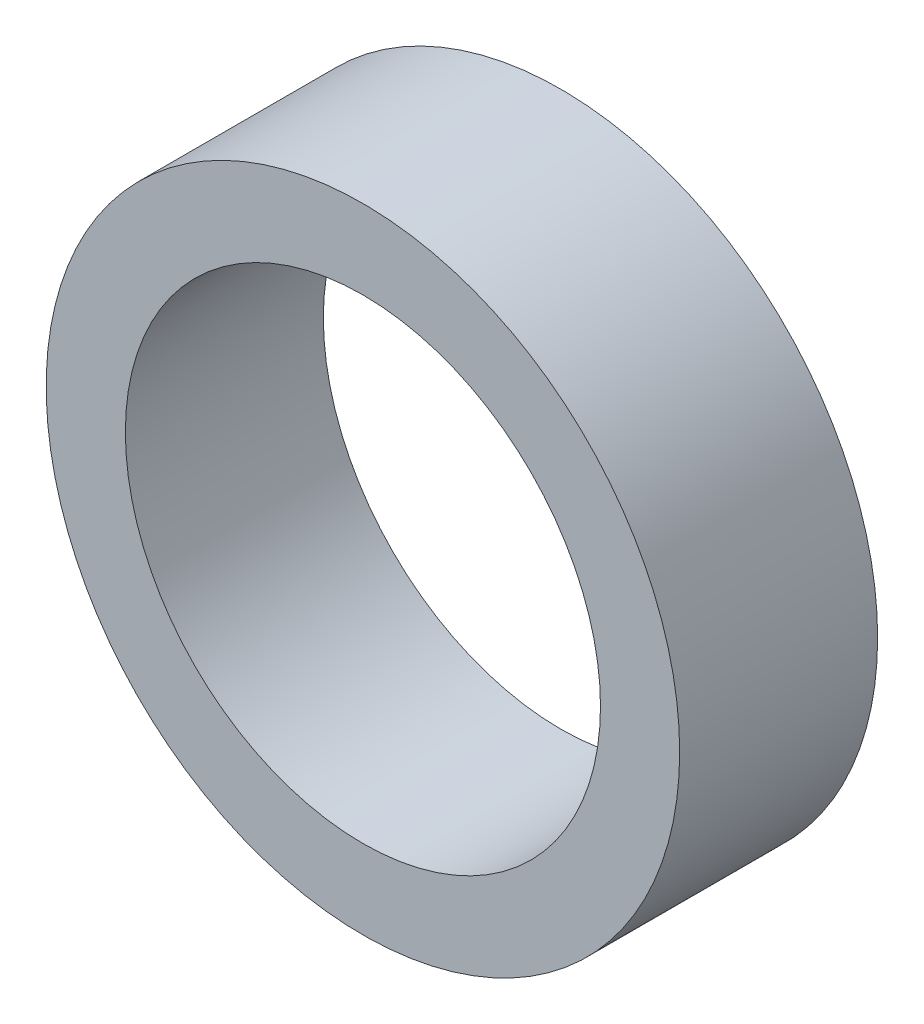
from build123d import *

# Parameters (mm, degrees)
CROQUIS3_R              = 16
SALIENTE_EXTRUIR2_DEPTH = 10
CROQUIS4_R              = 12
CORTAR_EXTRUIR1_DEPTH   = 10
ESCALA1_SCALE           = 7


with BuildPart() as part:
    # Croquis3 → Saliente-Extruir2 (new body)
    with BuildSketch(Plane.XY):
        Circle(CROQUIS3_R)
    extrude(amount=SALIENTE_EXTRUIR2_DEPTH)

    # Croquis4 → Cortar-Extruir1 (cut)
    with BuildSketch(Plane.XY.offset(10)):
        Circle(CROQUIS4_R)
    extrude(amount=-CORTAR_EXTRUIR1_DEPTH, mode=Mode.SUBTRACT)


with BuildPart() as part_1:
    # Escala1: scaled about (0, 0, 5)
    add(part.part.scale(ESCALA1_SCALE).moved(Location((0, 0, -30))))


solid = part_1.part
